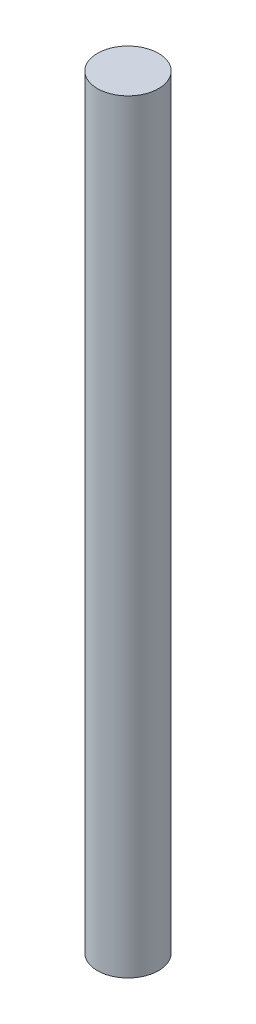
from build123d import *

# Parameters (mm, degrees)
SKETCH1_R           = 4
BOSS_EXTRUDE1_DEPTH = 100


with BuildPart() as part:
    # Sketch1 → Boss-Extrude1 (new body)
    with BuildSketch(Plane(origin=(0, 0, 0), x_dir=(1, 0, 0), z_dir=(0, 1, 0))):
        Circle(SKETCH1_R)
    extrude(amount=BOSS_EXTRUDE1_DEPTH)


solid = part.part
